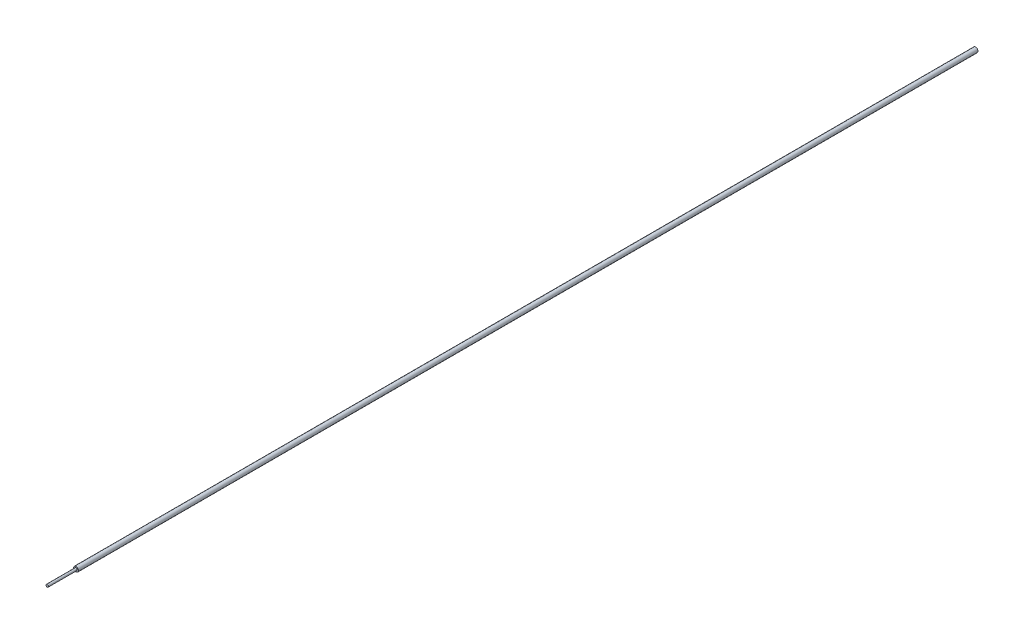
from build123d import *


with BuildPart() as part:
    # Sketch1 → Revolve1 (revolve)
    with BuildSketch(Plane(origin=(0, 0, 0), x_dir=(1, 0, 0), z_dir=(0, 1, 0)), mode=Mode.PRIVATE) as revolve1_sk:
        Polygon((0, 0), (0, 387), (1, 387), (1, 12), (0.5, 12), (0.5, 0), align=None)
    revolve(revolve1_sk.sketch.rotate(Axis((0, 0, 0), (0, 0, 1)), 180), axis=Axis((0, 0, 0), (0, 0, 1)))  # turned: the seam where the file's is


solid = part.part
